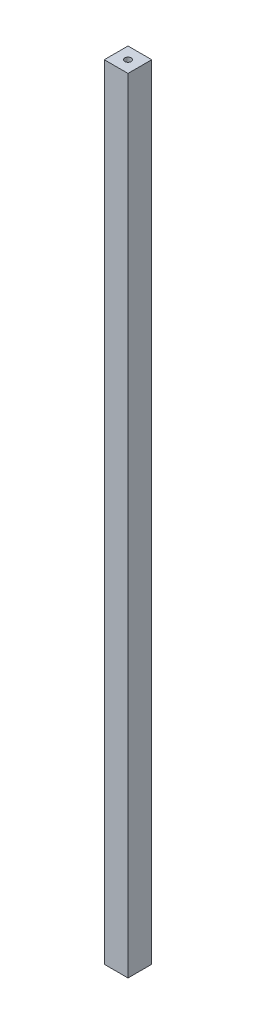
from build123d import *

# Parameters (mm, degrees)
SKETCH1_W             = 10
SKETCH1_H             = 10
BOSS_EXTRUDE1_DEPTH   = 330
F_6_32_TAPPED_HOLE1_D = 2.7051


with BuildPart() as part:
    # Sketch1 → Boss-Extrude1 (new body)
    with BuildSketch(Plane(origin=(0, 0, 0), x_dir=(1, 0, 0), z_dir=(0, 1, 0))):
        with Locations((5, 5)):
            Rectangle(SKETCH1_W, SKETCH1_H)
    extrude(amount=BOSS_EXTRUDE1_DEPTH)

    # #6-32 Tapped Hole1 (through all)
    with Locations(Plane(origin=(0, 330, 0), x_dir=(1, 0, 0), z_dir=(0, 1, 0))):
        with Locations((5, 5)):
            Hole(F_6_32_TAPPED_HOLE1_D / 2)


solid = part.part
